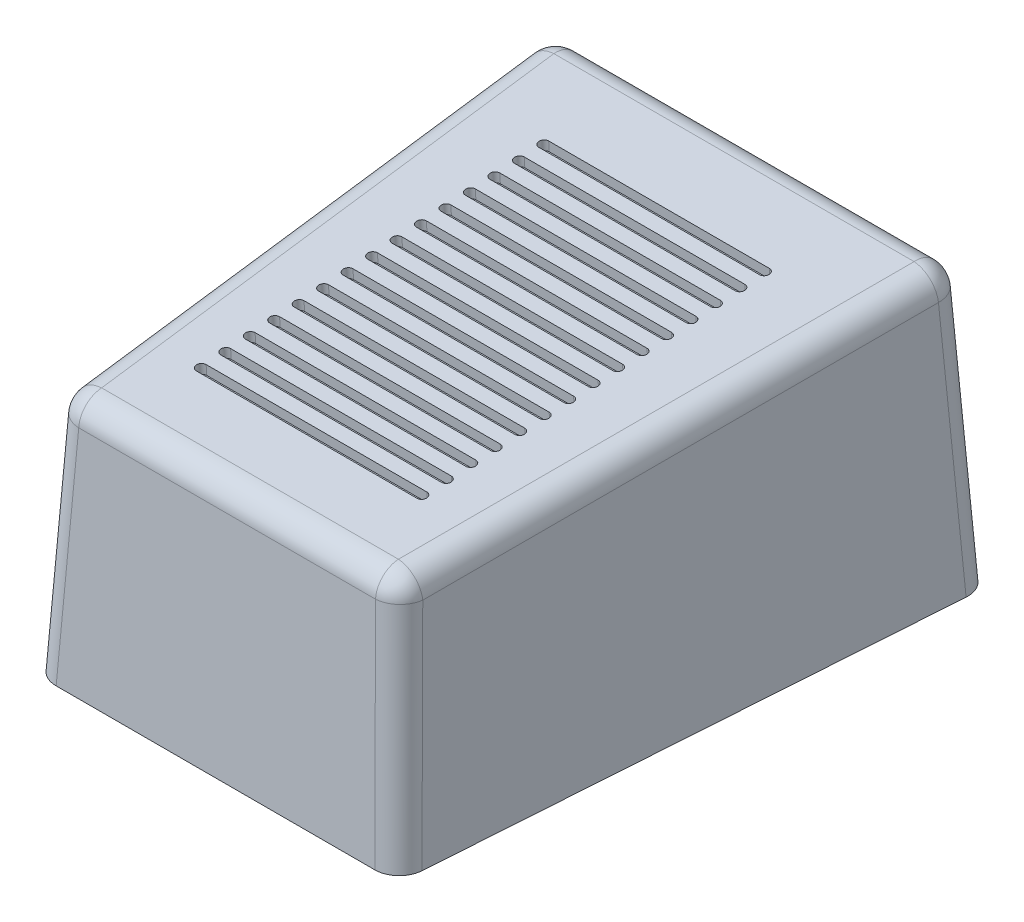
from build123d import *

# Parameters (mm, degrees)
BOSS_EXTRUDE1_DEPTH = 57
BOSS_EXTRUDE1_TAPER = 3
CUT_EXTRUDE5_DEPTH  = 91.003752482
FILLET1_R           = 5
CUT_EXTRUDE6_DEPTH  = 2


with BuildPart() as part:
    # Sketch1 → Boss-Extrude1 (new body)
    with BuildSketch(Plane(origin=(0, 0, 0), x_dir=(1, 0, 0), z_dir=(0, 1, 0))):
        Polygon((0, 0), (74.3, 0), (82.15, 113.789940148), (-7.85, 113.789940148), align=None)
    extrude(amount=BOSS_EXTRUDE1_DEPTH, taper=BOSS_EXTRUDE1_TAPER)

    # Sketch3 → Cut-Extrude5 (cut, through all, along a direction that is not the sketch's normal)
    with BuildSketch(Plane(origin=(0, 0, 0), x_dir=(0.068634232, -0.003605517, 0.997635375), z_dir=(-0.996261657, 0.052335956, 0.06872887))):
        Polygon((-111.065324518, 56.677595682), (-2.994323871, 57.067784774), (-2.623000223, 49.990855578), align=None)
    extrude(amount=-CUT_EXTRUDE5_DEPTH, dir=(-1, 0, 0), mode=Mode.SUBTRACT)

    # Fillet1
    fillet1_edges = [part.edges().sort_by_distance(p)[0] for p in [
        (37.15, 57, -110.802696729),
        (1.22124645, 24.965738369, -1.308398906),
        (73.07875355, 24.965738369, -1.308398906),
        (75.403541725, 53.465738369, -56.709747271),
        (37.15, 49.931476738, -2.616797812),
        (-1.103541725, 53.465738369, -56.709747271),
        (-6.249788175, 28.5, -112.296318439),
        (80.549788175, 28.5, -112.296318439),
    ]]
    fillet(fillet1_edges, radius=FILLET1_R)

    # Sketch4 → Cut-Extrude6 (cut)
    with BuildSketch(Plane(origin=(0, 49.548983776, 3.237373336), x_dir=(1, 0, 0), z_dir=(0, 0.997872359, 0.065197813))):
        with BuildLine():
            Line((14.329245801, 94.210038911), (59.329245801, 94.210038911))
            ThreePointArc((59.329245801, 94.210038911), (60.329245801, 93.210038911), (59.329245801, 92.210038911))
            Line((59.329245801, 92.210038911), (14.329245801, 92.210038911))
            ThreePointArc((14.329245801, 92.210038911), (13.329245801, 93.210038911), (14.329245801, 94.210038911))
        make_face()
        with BuildLine():
            Line((14.329245801, 89.210038911), (59.329245801, 89.210038911))
            ThreePointArc((59.329245801, 89.210038911), (60.329245801, 88.210038911), (59.329245801, 87.210038911))
            Line((59.329245801, 87.210038911), (14.329245801, 87.210038911))
            ThreePointArc((14.329245801, 87.210038911), (13.329245801, 88.210038911), (14.329245801, 89.210038911))
        make_face()
        with BuildLine():
            Line((14.329245801, 84.210038911), (59.329245801, 84.210038911))
            ThreePointArc((59.329245801, 84.210038911), (60.329245801, 83.210038911), (59.329245801, 82.210038911))
            Line((59.329245801, 82.210038911), (14.329245801, 82.210038911))
            ThreePointArc((14.329245801, 82.210038911), (13.329245801, 83.210038911), (14.329245801, 84.210038911))
        make_face()
        with BuildLine():
            Line((14.329245801, 79.210038911), (59.329245801, 79.210038911))
            ThreePointArc((59.329245801, 79.210038911), (60.329245801, 78.210038911), (59.329245801, 77.210038911))
            Line((59.329245801, 77.210038911), (14.329245801, 77.210038911))
            ThreePointArc((14.329245801, 77.210038911), (13.329245801, 78.210038911), (14.329245801, 79.210038911))
        make_face()
        with BuildLine():
            Line((14.329245801, 74.210038911), (59.329245801, 74.210038911))
            ThreePointArc((59.329245801, 74.210038911), (60.329245801, 73.210038911), (59.329245801, 72.210038911))
            Line((59.329245801, 72.210038911), (14.329245801, 72.210038911))
            ThreePointArc((14.329245801, 72.210038911), (13.329245801, 73.210038911), (14.329245801, 74.210038911))
        make_face()
        with BuildLine():
            Line((14.329245801, 69.210038911), (59.329245801, 69.210038911))
            ThreePointArc((59.329245801, 69.210038911), (60.329245801, 68.210038911), (59.329245801, 67.210038911))
            Line((59.329245801, 67.210038911), (14.329245801, 67.210038911))
            ThreePointArc((14.329245801, 67.210038911), (13.329245801, 68.210038911), (14.329245801, 69.210038911))
        make_face()
        with BuildLine():
            Line((14.329245801, 64.210038911), (59.329245801, 64.210038911))
            ThreePointArc((59.329245801, 64.210038911), (60.329245801, 63.210038911), (59.329245801, 62.210038911))
            Line((59.329245801, 62.210038911), (14.329245801, 62.210038911))
            ThreePointArc((14.329245801, 62.210038911), (13.329245801, 63.210038911), (14.329245801, 64.210038911))
        make_face()
        with BuildLine():
            Line((14.329245801, 59.210038911), (59.329245801, 59.210038911))
            ThreePointArc((59.329245801, 59.210038911), (60.329245801, 58.210038911), (59.329245801, 57.210038911))
            Line((59.329245801, 57.210038911), (14.329245801, 57.210038911))
            ThreePointArc((14.329245801, 57.210038911), (13.329245801, 58.210038911), (14.329245801, 59.210038911))
        make_face()
        with BuildLine():
            Line((14.329245801, 54.210038911), (59.329245801, 54.210038911))
            ThreePointArc((59.329245801, 54.210038911), (60.329245801, 53.210038911), (59.329245801, 52.210038911))
            Line((59.329245801, 52.210038911), (14.329245801, 52.210038911))
            ThreePointArc((14.329245801, 52.210038911), (13.329245801, 53.210038911), (14.329245801, 54.210038911))
        make_face()
        with BuildLine():
            Line((14.329245801, 49.210038911), (59.329245801, 49.210038911))
            ThreePointArc((59.329245801, 49.210038911), (60.329245801, 48.210038911), (59.329245801, 47.210038911))
            Line((59.329245801, 47.210038911), (14.329245801, 47.210038911))
            ThreePointArc((14.329245801, 47.210038911), (13.329245801, 48.210038911), (14.329245801, 49.210038911))
        make_face()
        with BuildLine():
            Line((14.329245801, 44.210038911), (59.329245801, 44.210038911))
            ThreePointArc((59.329245801, 44.210038911), (60.329245801, 43.210038911), (59.329245801, 42.210038911))
            Line((59.329245801, 42.210038911), (14.329245801, 42.210038911))
            ThreePointArc((14.329245801, 42.210038911), (13.329245801, 43.210038911), (14.329245801, 44.210038911))
        make_face()
        with BuildLine():
            Line((14.329245801, 39.210038911), (59.329245801, 39.210038911))
            ThreePointArc((59.329245801, 39.210038911), (60.329245801, 38.210038911), (59.329245801, 37.210038911))
            Line((59.329245801, 37.210038911), (14.329245801, 37.210038911))
            ThreePointArc((14.329245801, 37.210038911), (13.329245801, 38.210038911), (14.329245801, 39.210038911))
        make_face()
        with BuildLine():
            Line((14.329245801, 34.210038911), (59.329245801, 34.210038911))
            ThreePointArc((59.329245801, 34.210038911), (60.329245801, 33.210038911), (59.329245801, 32.210038911))
            Line((59.329245801, 32.210038911), (14.329245801, 32.210038911))
            ThreePointArc((14.329245801, 32.210038911), (13.329245801, 33.210038911), (14.329245801, 34.210038911))
        make_face()
        with BuildLine():
            Line((14.329245801, 29.210038911), (59.329245801, 29.210038911))
            ThreePointArc((59.329245801, 29.210038911), (60.329245801, 28.210038911), (59.329245801, 27.210038911))
            Line((59.329245801, 27.210038911), (14.329245801, 27.210038911))
            ThreePointArc((14.329245801, 27.210038911), (13.329245801, 28.210038911), (14.329245801, 29.210038911))
        make_face()
        with BuildLine():
            Line((14.329245801, 24.210038911), (59.329245801, 24.210038911))
            ThreePointArc((59.329245801, 24.210038911), (60.329245801, 23.210038911), (59.329245801, 22.210038911))
            Line((59.329245801, 22.210038911), (14.329245801, 22.210038911))
            ThreePointArc((14.329245801, 22.210038911), (13.329245801, 23.210038911), (14.329245801, 24.210038911))
        make_face()
    extrude(amount=-CUT_EXTRUDE6_DEPTH, mode=Mode.SUBTRACT)


solid = part.part
